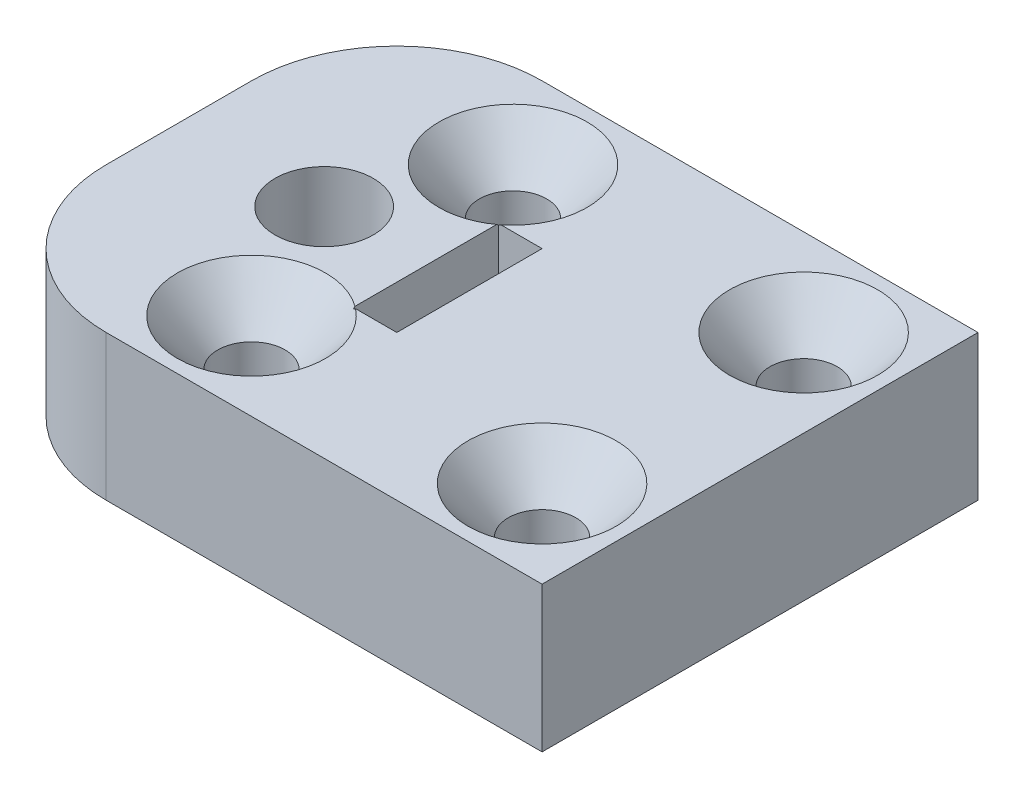
from build123d import *

# Parameters (mm, degrees)
SKETCH1_W                                         = 25.4
SKETCH1_H                                         = 19.05
SKETCH1_R                                         = 2.1463
SKETCH1_W_2                                       = 1.905
SKETCH1_H_2                                       = 6.35
BOSS_EXTRUDE1_DEPTH                               = 6.35
CSK_FOR_4_FLAT_HEAD_SOCKET_CAP_SCREW1_D           = 2.9464
CSK_FOR_4_FLAT_HEAD_SOCKET_CAP_SCREW1_CSINK_D     = 6.477
CSK_FOR_4_FLAT_HEAD_SOCKET_CAP_SCREW1_CSINK_ANGLE = 82
FILLET1_R                                         = 6.35


with BuildPart() as part:
    # Sketch1 → Boss-Extrude1 (new body)
    with BuildSketch(Plane(origin=(0, 0, 0), x_dir=(1, 0, 0), z_dir=(0, 1, 0))):
        with Locations((6.35, 0)):
            Rectangle(SKETCH1_W, SKETCH1_H)
        Circle(SKETCH1_R, mode=Mode.SUBTRACT)
        with Locations((5.3975, 0)):
            Rectangle(SKETCH1_W_2, SKETCH1_H_2, mode=Mode.SUBTRACT)
    extrude(amount=BOSS_EXTRUDE1_DEPTH)

    # CSK for #4 Flat Head Socket Cap Screw1 (through all)
    with Locations(Plane(origin=(0, 6.35, 0), x_dir=(1, 0, 0), z_dir=(0, 1, 0))):
        with Locations((2.54, 5.715), (15.24, -5.715), (2.54, -5.715), (15.24, 5.715)):
            CounterSinkHole(CSK_FOR_4_FLAT_HEAD_SOCKET_CAP_SCREW1_D / 2, CSK_FOR_4_FLAT_HEAD_SOCKET_CAP_SCREW1_CSINK_D / 2, counter_sink_angle=CSK_FOR_4_FLAT_HEAD_SOCKET_CAP_SCREW1_CSINK_ANGLE)

    # Fillet1
    fillet1_edges = [part.edges().sort_by_distance(p)[0] for p in [
        (-6.35, 3.175, -9.525),
        (-6.35, 3.175, 9.525),
    ]]
    fillet(fillet1_edges, radius=FILLET1_R)


solid = part.part
